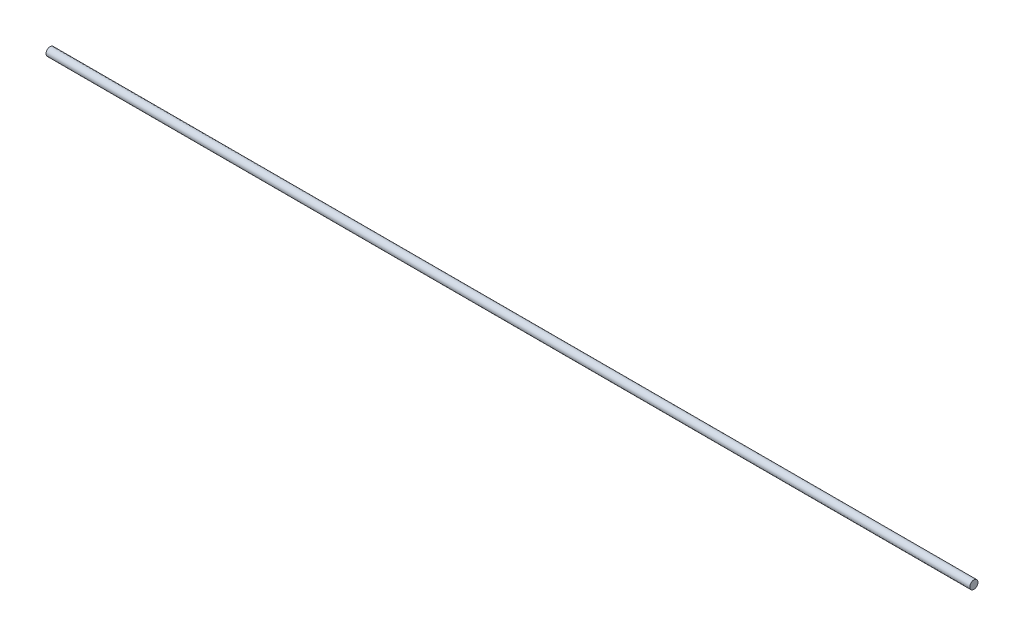
from build123d import *

# Parameters (mm, degrees)
SKETCH1_R           = 3.175
BOSS_EXTRUDE1_DEPTH = 711.2


with BuildPart() as part:
    # Sketch1 → Boss-Extrude1 (new body)
    with BuildSketch(Plane(origin=(0, 0, 0), x_dir=(0, 0, -1), z_dir=(1, 0, 0))):
        Circle(SKETCH1_R)
    extrude(amount=BOSS_EXTRUDE1_DEPTH)


solid = part.part
